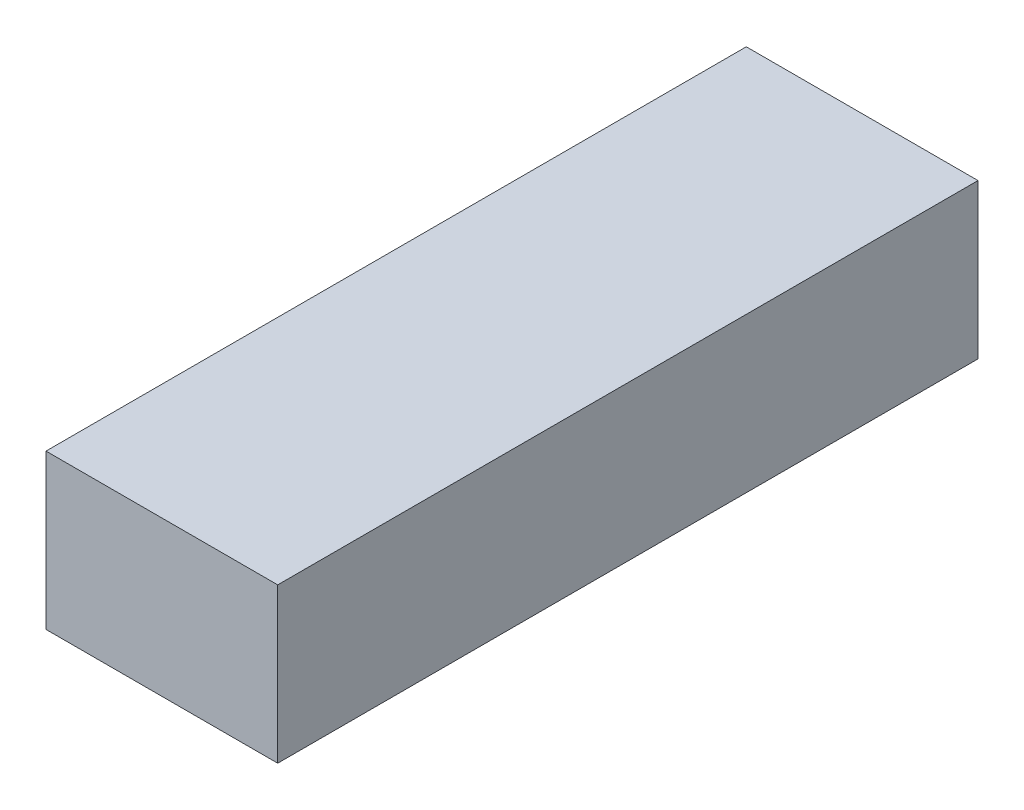
from build123d import *

# Parameters (mm, degrees)
SKETCH1_W           = 45
SKETCH1_H           = 30
BOSS_EXTRUDE1_DEPTH = 136


with BuildPart() as part:
    # Sketch1 → Boss-Extrude1 (new body)
    with BuildSketch(Plane.XY):
        Rectangle(SKETCH1_W, SKETCH1_H)
    extrude(amount=BOSS_EXTRUDE1_DEPTH)


solid = part.part
